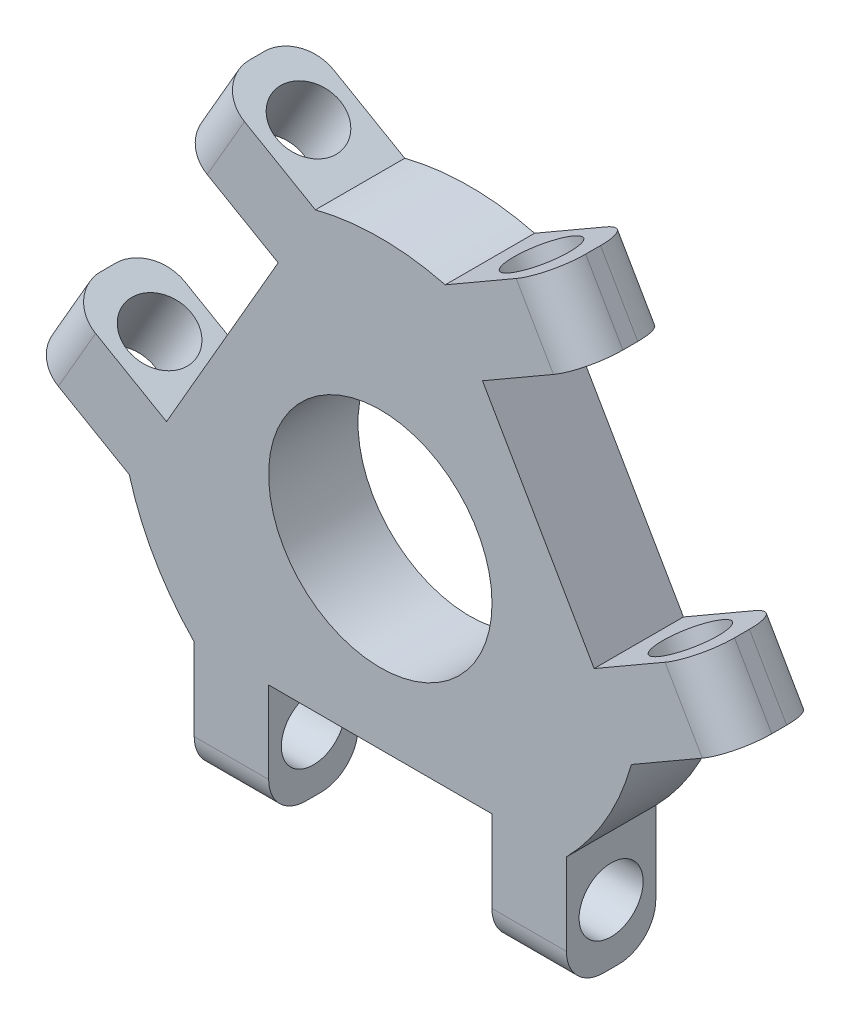
from build123d import *

# Parameters (mm, degrees)
SKETCH1_R                = 15
BOSS_EXTRUDE1_DEPTH      = 12
BOSS_EXTRUDE2_DEPTH      = 12
SKETCH3_R                = 4.3
CUT_EXTRUDE1_DEPTH       = 79.135824623
FILLET1_R                = 5
CIRPATTERN1_COUNT        = 3
FILLET1_OF_CIRPATTERN1_R = 5


with BuildPart() as part:
    # Sketch1 → Boss-Extrude1 (new body)
    with BuildSketch(Plane.XY):
        with BuildLine():
            Line((-8.720122643, 33.896304534), (-33.715122143, -9.396304534))
            ThreePointArc((-33.715122143, -9.396304534), (-30.310889132, -17.5), (-24.9949995, -24.5))
            Line((-24.9949995, -24.5), (24.9949995, -24.5))
            ThreePointArc((24.9949995, -24.5), (30.310889132, -17.5), (33.715122143, -9.396304534))
            Line((33.715122143, -9.396304534), (8.720122643, 33.896304534))
            ThreePointArc((8.720122643, 33.896304534), (0, 35), (-8.720122643, 33.896304534))
        make_face()
        Circle(SKETCH1_R, mode=Mode.SUBTRACT)
    extrude(amount=BOSS_EXTRUDE1_DEPTH)

    # Sketch2 → Boss-Extrude2 (add)
    with BuildSketch(Plane(origin=(0, 0, 0), x_dir=(-1, 0, 0), z_dir=(0, 0, -1))):
        Polygon((33.715122143, -9.396304534), (47.571528603, -1.396304534), (42.571528603, 7.263949503), (28.715122143, -0.736050497), align=None)
        Polygon((13.720122643, 25.236050497), (8.720122643, 33.896304534), (22.576529103, 41.896304534), (27.576529103, 33.236050497), align=None)
    boss_extrude2 = extrude(amount=-BOSS_EXTRUDE2_DEPTH)

    # Sketch3 → Cut-Extrude1 (cut, through all)
    with BuildSketch(Plane(origin=(-12.49749975, -21.646304534, 0), x_dir=(0.866025404, -0.5, 0), z_dir=(-0.5, -0.866025404, 0))):
        with Locations((-32.5, 6)):
            Circle(SKETCH3_R)
    cut_extrude1 = extrude(amount=-CUT_EXTRUDE1_DEPTH, mode=Mode.SUBTRACT)

    # Fillet1
    fillet1_edges = [part.edges().sort_by_distance(p)[0] for p in [
        (-45.071528603, 2.933822484, 12),
        (-45.071528603, 2.933822484, 0),
        (-25.076529103, 37.566177516, 12),
        (-25.076529103, 37.566177516, 0),
    ]]
    fillet(fillet1_edges, radius=FILLET1_R)

    # CirPattern1: Boss-Extrude2, Cut-Extrude1 ×3 about axis
    cirpattern1_axis = Axis((0, 0, 0), (0, 0, 1))
    for i in range(1, CIRPATTERN1_COUNT):
        add(boss_extrude2.rotate(cirpattern1_axis, i * 360 / CIRPATTERN1_COUNT))
        add(cut_extrude1.rotate(cirpattern1_axis, i * 360 / CIRPATTERN1_COUNT), mode=Mode.SUBTRACT)

    # Fillet1 of CirPattern1
    fillet1_of_cirpattern1_edges = [part.edges().sort_by_distance(p)[0] for p in [
        (19.9949995, -40.5, 12),
        (19.9949995, -40.5, 0),
        (-19.9949995, -40.5, 12),
        (-19.9949995, -40.5, 0),
        (25.076529103, 37.566177516, 12),
        (25.076529103, 37.566177516, 0),
        (45.071528603, 2.933822484, 12),
        (45.071528603, 2.933822484, 0),
    ]]
    fillet(fillet1_of_cirpattern1_edges, radius=FILLET1_OF_CIRPATTERN1_R)


solid = part.part
